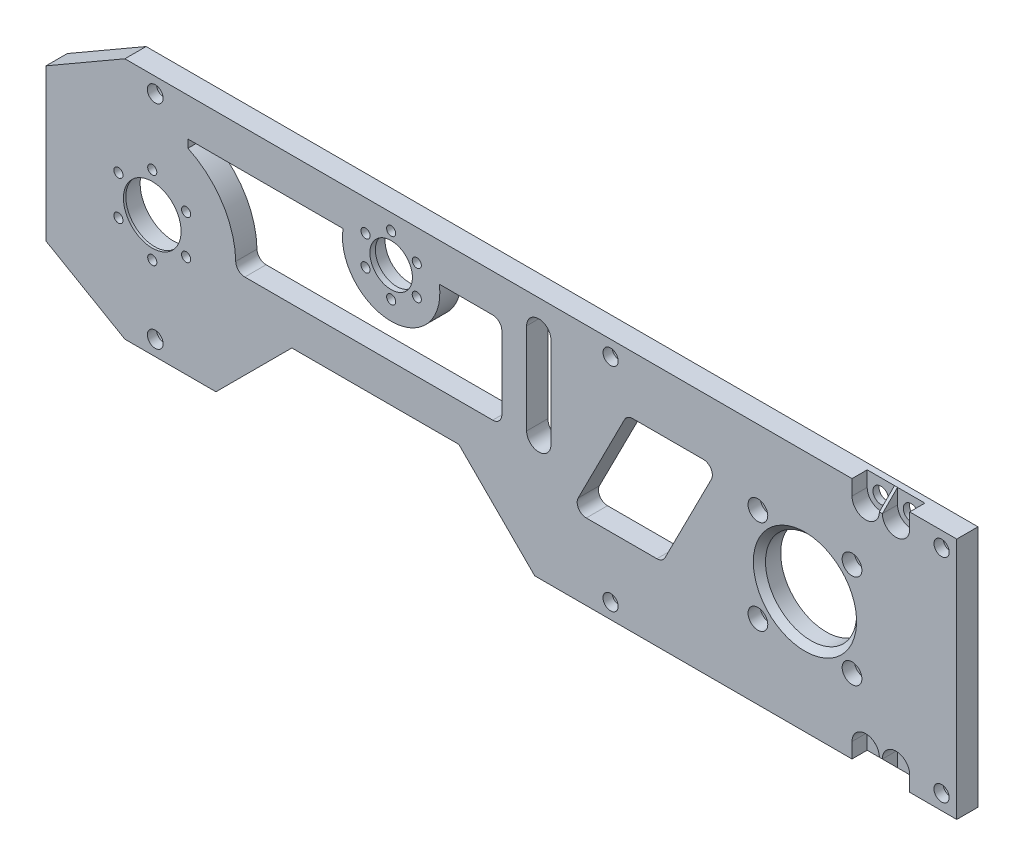
from build123d import *

# Parameters (mm, degrees)
SKETCH1_W           = 300
SKETCH1_H           = 80
BOSS_EXTRUDE1_DEPTH = 7
CHAMFER1_SIZE       = 15
CHAMFER1_SIZE2      = 25.980762114
CHAMFER3_SIZE       = 15
CHAMFER3_SIZE2      = 25.980762114
SKETCH2_R           = 11
CUT_EXTRUDE1_DEPTH  = 10
SKETCH3_R           = 11
SKETCH3_R_2         = 9.5
BOSS_EXTRUDE3_DEPTH = 0.8
CUT_EXTRUDE2_DEPTH  = 8
SKETCH5_R           = 15
CUT_EXTRUDE3_DEPTH  = 8
CUT_EXTRUDE4_DEPTH  = 8
SKETCH7_R           = 8
CUT_EXTRUDE6_DEPTH  = 8
SKETCH8_R           = 8
SKETCH8_R_2         = 7
BOSS_EXTRUDE4_DEPTH = 1.8
SKETCH9_R           = 1.5
CUT_EXTRUDE7_DEPTH  = 8
SKETCH10_R          = 12
CUT_EXTRUDE8_DEPTH  = 1
SKETCH11_R          = 1.5
CUT_EXTRUDE9_DEPTH  = 8
SKETCH12_R          = 2.6
SKETCH12_R_2        = 2.5
CUT_EXTRUDE10_DEPTH = 8
SKETCH13_R          = 4
CUT_EXTRUDE11_DEPTH = 4
SKETCH14_R          = 1.75
CUT_EXTRUDE12_DEPTH = 8
CUT_EXTRUDE13_DEPTH = 8
CUT_EXTRUDE14_DEPTH = 8
CUT_EXTRUDE15_DEPTH = 8
SKETCH18_R          = 3.25
CUT_EXTRUDE16_DEPTH = 4
CHAMFER4_SIZE       = 2
FILLET1_R           = 3
FILLET2_R           = 3
SKETCH19_R          = 2.6
CUT_EXTRUDE17_DEPTH = 8
SKETCH20_R          = 4.5
CUT_EXTRUDE18_DEPTH = 5
SKETCH21_W          = 9
SKETCH21_H          = 5
CUT_EXTRUDE19_DEPTH = 5
CHAMFER5_SIZE       = 5


with BuildPart() as part:
    # Sketch1 → Boss-Extrude1 (new body)
    with BuildSketch(Plane.XY):
        with Locations((150, 40)):
            Rectangle(SKETCH1_W, SKETCH1_H)
    extrude(amount=BOSS_EXTRUDE1_DEPTH)

    # Chamfer1
    chamfer1_edges = [part.edges().sort_by_distance(p)[0] for p in [
        (0, 0, 3.5),
    ]]
    chamfer1_side = [part.faces().sort_by_distance(p)[0] for p in [
        (0, 40, 3.5),
    ]]
    chamfer(chamfer1_edges, length=CHAMFER1_SIZE, length2=CHAMFER1_SIZE2, reference=chamfer1_side[0])

    # Chamfer3
    chamfer3_edges = [part.edges().sort_by_distance(p)[0] for p in [
        (0, 80, 3.5),
    ]]
    chamfer3_side = [part.faces().sort_by_distance(p)[0] for p in [
        (0, 47.5, 3.5),
    ]]
    chamfer(chamfer3_edges, length=CHAMFER3_SIZE, length2=CHAMFER3_SIZE2, reference=chamfer3_side[0])

    # Sketch2 → Cut-Extrude1 (cut)
    with BuildSketch(Plane.XY.offset(7)):
        with Locations((35, 40)):
            Circle(SKETCH2_R)
    extrude(amount=-CUT_EXTRUDE1_DEPTH, mode=Mode.SUBTRACT)

    # Sketch3 → Boss-Extrude3 (add)
    with BuildSketch(Plane.XY.offset(7)):
        with Locations((35, 40)):
            Circle(SKETCH3_R)
        with Locations((35, 40)):
            Circle(SKETCH3_R_2, mode=Mode.SUBTRACT)
    extrude(amount=-BOSS_EXTRUDE3_DEPTH)

    # Sketch4 → Cut-Extrude2 (cut, through all)
    with BuildSketch(Plane.XY.offset(7)):
        with BuildLine():
            Line((163.324941262, 70), (163.324941262, 40))
            ThreePointArc((163.324941262, 40), (162.324941262, 39), (161.324941262, 40))
            Line((161.324941262, 40), (161.324941262, 70))
            ThreePointArc((161.324941262, 70), (162.324941262, 71), (163.324941262, 70))
        make_face()
    extrude(amount=-CUT_EXTRUDE2_DEPTH, mode=Mode.SUBTRACT)

    # Sketch5 → Cut-Extrude3 (cut, through all)
    with BuildSketch(Plane.XY.offset(7)):
        with Locations((250, 40)):
            Circle(SKETCH5_R)
    extrude(amount=-CUT_EXTRUDE3_DEPTH, mode=Mode.SUBTRACT)

    # Sketch6 → Cut-Extrude4 (cut)
    with BuildSketch(Plane(origin=(0, 0, 0), x_dir=(-1, 0, 0), z_dir=(0, 0, -1))):
        with BuildLine():
            Line((-158.324941262, 70), (-158.324941262, 40))
            ThreePointArc((-158.324941262, 40), (-162.324941262, 36), (-166.324941262, 40))
            Line((-166.324941262, 40), (-166.324941262, 70))
            ThreePointArc((-166.324941262, 70), (-162.324941262, 74), (-158.324941262, 70))
        make_face()
    extrude(amount=-CUT_EXTRUDE4_DEPTH, mode=Mode.SUBTRACT)

    # Sketch7 → Cut-Extrude6 (cut, through all)
    with BuildSketch(Plane.XY.offset(7)):
        with Locations((113.691629607, 65)):
            Circle(SKETCH7_R)
    extrude(amount=-CUT_EXTRUDE6_DEPTH, mode=Mode.SUBTRACT)

    # Sketch8 → Boss-Extrude4 (add)
    with BuildSketch(Plane.XY.offset(7)):
        with Locations((113.691629607, 65)):
            Circle(SKETCH8_R)
        with Locations((113.691629607, 65)):
            Circle(SKETCH8_R_2, mode=Mode.SUBTRACT)
    extrude(amount=-BOSS_EXTRUDE4_DEPTH)

    # Sketch9 → Cut-Extrude7 (cut, through all)
    with BuildSketch(Plane(origin=(0, 0, 0), x_dir=(-1, 0, 0), z_dir=(0, 0, -1))):
        with Locations((-113.691629607, 74.75)):
            Circle(SKETCH9_R)
        with Locations((-105.24788192, 69.875)):
            Circle(SKETCH9_R)
        with Locations((-105.24788192, 60.125)):
            Circle(SKETCH9_R)
        with Locations((-113.691629607, 55.25)):
            Circle(SKETCH9_R)
        with Locations((-122.135377294, 60.125)):
            Circle(SKETCH9_R)
        with Locations((-122.135377294, 69.875)):
            Circle(SKETCH9_R)
    extrude(amount=-CUT_EXTRUDE7_DEPTH, mode=Mode.SUBTRACT)

    # Sketch10 → Cut-Extrude8 (cut)
    with BuildSketch(Plane(origin=(0, 0, 0), x_dir=(-1, 0, 0), z_dir=(0, 0, -1))):
        with Locations((-113.691629607, 65)):
            Circle(SKETCH10_R)
    extrude(amount=-CUT_EXTRUDE8_DEPTH, mode=Mode.SUBTRACT)

    # Sketch11 → Cut-Extrude9 (cut, through all)
    with BuildSketch(Plane(origin=(0, 0, 0), x_dir=(-1, 0, 0), z_dir=(0, 0, -1))):
        with Locations((-35, 52.875)):
            Circle(SKETCH11_R)
        with Locations((-23.849922926, 46.4375)):
            Circle(SKETCH11_R)
        with Locations((-23.849922926, 33.5625)):
            Circle(SKETCH11_R)
        with Locations((-35, 27.125)):
            Circle(SKETCH11_R)
        with Locations((-46.150077074, 33.5625)):
            Circle(SKETCH11_R)
        with Locations((-46.150077074, 46.4375)):
            Circle(SKETCH11_R)
    extrude(amount=-CUT_EXTRUDE9_DEPTH, mode=Mode.SUBTRACT)

    # Sketch12 → Cut-Extrude10 (cut, through all)
    with BuildSketch(Plane(origin=(0, 0, 0), x_dir=(-1, 0, 0), z_dir=(0, 0, -1))):
        with Locations((-35.980762114, 75)):
            Circle(SKETCH12_R)
        with Locations((-185.980762114, 75)):
            Circle(SKETCH12_R_2)
        with Locations((-295, 75)):
            Circle(SKETCH12_R_2)
        with Locations((-35.980762114, 5)):
            Circle(SKETCH12_R)
        with Locations((-185.980762114, 5)):
            Circle(SKETCH12_R_2)
        with Locations((-295, 5)):
            Circle(SKETCH12_R_2)
    extrude(amount=-CUT_EXTRUDE10_DEPTH, mode=Mode.SUBTRACT)

    # Sketch13 → Cut-Extrude11 (cut)
    with BuildSketch(Plane(origin=(0, 0, 0), x_dir=(-1, 0, 0), z_dir=(0, 0, -1))):
        with Locations((-295, 75)):
            Circle(SKETCH13_R)
        with Locations((-185.980762114, 75)):
            Circle(SKETCH13_R)
        with Locations((-35.980762114, 75)):
            Circle(SKETCH13_R)
        with Locations((-35.980762114, 5)):
            Circle(SKETCH13_R)
        with Locations((-185.980762114, 5)):
            Circle(SKETCH13_R)
        with Locations((-295, 5)):
            Circle(SKETCH13_R)
    extrude(amount=-CUT_EXTRUDE11_DEPTH, mode=Mode.SUBTRACT)

    # Sketch14 → Cut-Extrude12 (cut, through all)
    with BuildSketch(Plane.XY.offset(7)):
        with Locations((234.5, 55.5)):
            Circle(SKETCH14_R)
        with Locations((265.5, 55.5)):
            Circle(SKETCH14_R)
        with Locations((234.5, 24.5)):
            Circle(SKETCH14_R)
        with Locations((265.5, 24.5)):
            Circle(SKETCH14_R)
    extrude(amount=-CUT_EXTRUDE12_DEPTH, mode=Mode.SUBTRACT)

    # Sketch15 → Cut-Extrude13 (cut, through all)
    with BuildSketch(Plane.XY.offset(7)):
        Polygon((55.980762114, 0), (80.980762114, 25), (135.980762114, 25), (160.980762114, 0), align=None)
    extrude(amount=-CUT_EXTRUDE13_DEPTH, mode=Mode.SUBTRACT)

    # Sketch16 → Cut-Extrude14 (cut, through all)
    with BuildSketch(Plane.XY.offset(7)):
        Polygon((173.074478381, 25), (191.398328859, 61), (221.398328859, 61), (203.074478381, 25), align=None)
    extrude(amount=-CUT_EXTRUDE14_DEPTH, mode=Mode.SUBTRACT)

    # Sketch17 → Cut-Extrude15 (cut, through all)
    with BuildSketch(Plane.XY.offset(7)):
        with BuildLine():
            Line((129.537407736, 67.5), (150.148643313, 67.5))
            Line((150.148643313, 67.5), (150.148643313, 37.5))
            Line((150.148643313, 37.5), (62.386127875, 37.5))
            ThreePointArc((62.386127875, 37.5), (58.87799347, 53.641533192), (46.754644264, 64.861181352))
            Line((46.754644264, 64.861181352), (46.754644264, 67.5))
            Line((46.754644264, 67.5), (97.845851478, 67.5))
            ThreePointArc((97.845851478, 67.5), (113.691629607, 48.958220657), (129.537407736, 67.5))
        make_face()
    extrude(amount=-CUT_EXTRUDE15_DEPTH, mode=Mode.SUBTRACT)

    # Sketch18 → Cut-Extrude16 (cut)
    with BuildSketch(Plane.XY.offset(7)):
        with Locations((234.5, 55.5)):
            Circle(SKETCH18_R)
        with Locations((265.5, 55.5)):
            Circle(SKETCH18_R)
        with Locations((265.5, 24.5)):
            Circle(SKETCH18_R)
        with Locations((234.5, 24.5)):
            Circle(SKETCH18_R)
    extrude(amount=-CUT_EXTRUDE16_DEPTH, mode=Mode.SUBTRACT)

    # Chamfer4
    chamfer4_edges = [part.edges().sort_by_distance(p)[0] for p in [
        (235, 40, 7),
    ]]
    chamfer(chamfer4_edges, length=CHAMFER4_SIZE)

    # Fillet1
    fillet1_edges = [part.edges().sort_by_distance(p)[0] for p in [
        (203.074478381, 25, 3.5),
        (173.074478381, 25, 3.5),
        (191.398328859, 61, 3.5),
        (221.398328859, 61, 3.5),
    ]]
    fillet(fillet1_edges, radius=FILLET1_R)

    # Fillet2
    fillet2_edges = [part.edges().sort_by_distance(p)[0] for p in [
        (150.148643313, 67.5, 3.5),
        (150.148643313, 37.5, 3.5),
        (62.386127875, 37.5, 3.5),
    ]]
    fillet(fillet2_edges, radius=FILLET2_R)

    # Sketch19 → Cut-Extrude17 (cut, through all)
    with BuildSketch(Plane(origin=(0, 0, 0), x_dir=(-1, 0, 0), z_dir=(0, 0, -1))):
        with Locations((-280, 75)):
            Circle(SKETCH19_R)
        with Locations((-270, 75)):
            Circle(SKETCH19_R)
        with Locations((-270, 5)):
            Circle(SKETCH19_R)
        with Locations((-280, 5)):
            Circle(SKETCH19_R)
    extrude(amount=-CUT_EXTRUDE17_DEPTH, mode=Mode.SUBTRACT)

    # Sketch20 → Cut-Extrude18 (cut)
    with BuildSketch(Plane.XY.offset(7)):
        with Locations((270, 75)):
            Circle(SKETCH20_R)
        with Locations((280, 75)):
            Circle(SKETCH20_R)
        with Locations((280, 5)):
            Circle(SKETCH20_R)
        with Locations((270, 5)):
            Circle(SKETCH20_R)
    extrude(amount=-CUT_EXTRUDE18_DEPTH, mode=Mode.SUBTRACT)

    # Sketch21 → Cut-Extrude19 (cut)
    with BuildSketch(Plane.XY.offset(7)):
        with Locations((270, 77.5)):
            Rectangle(SKETCH21_W, SKETCH21_H)
        with Locations((280, 77.5)):
            Rectangle(SKETCH21_W, SKETCH21_H)
        with Locations((270, 2.5)):
            Rectangle(SKETCH21_W, SKETCH21_H)
        with Locations((280, 2.5)):
            Rectangle(SKETCH21_W, SKETCH21_H)
    extrude(amount=-CUT_EXTRUDE19_DEPTH, mode=Mode.SUBTRACT)

    # Chamfer5
    chamfer5_edges = [part.edges().sort_by_distance(p)[0] for p in [
        (275, 0, 7),
        (275, 80, 7),
    ]]
    chamfer(chamfer5_edges, length=CHAMFER5_SIZE)


solid = part.part
